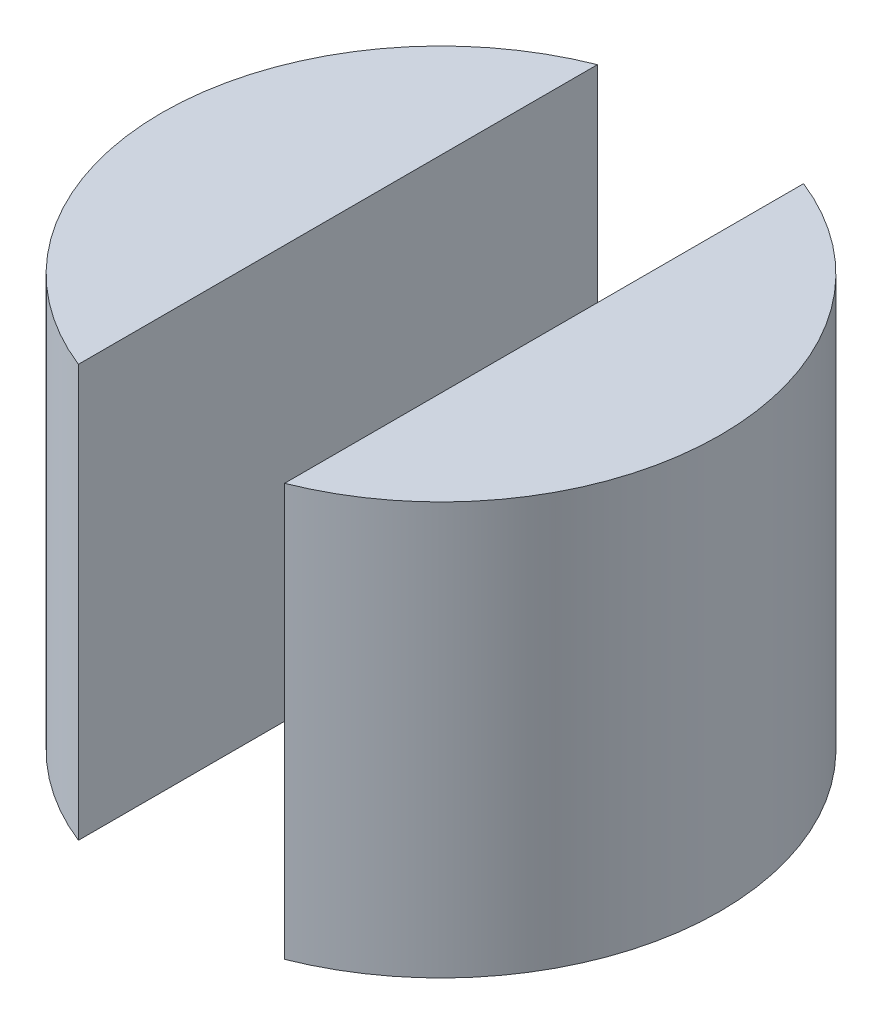
from build123d import *

# Parameters (mm, degrees)
BOSS_EXTRUDE1_DEPTH   = 6
BOSS_EXTRUDE1_2_DEPTH = 6


with BuildPart() as part:
    # Sketch2 → Boss-Extrude1 (new body)
    with BuildSketch(Plane(origin=(0, 0, 0), x_dir=(1, 0, 0), z_dir=(0, 1, 0))):
        with BuildLine():
            Line((-1.5, 3.777027027), (-1.5, -3.777027027))
            ThreePointArc((-1.5, -3.777027027), (-4.063979966, 0), (-1.5, 3.777027027))
        make_face()
    extrude(amount=BOSS_EXTRUDE1_DEPTH)


with BuildPart() as body_2:
    # Sketch2 → Boss-Extrude1 2 (new body)
    with BuildSketch(Plane(origin=(0, 0, 0), x_dir=(1, 0, 0), z_dir=(0, 1, 0))):
        with BuildLine():
            Line((1.5, 3.777027027), (1.5, -3.777027027))
            ThreePointArc((1.5, -3.777027027), (4.063979966, 0), (1.5, 3.777027027))
        make_face()
    extrude(amount=BOSS_EXTRUDE1_2_DEPTH)


solid = Compound([part.part, body_2.part])
